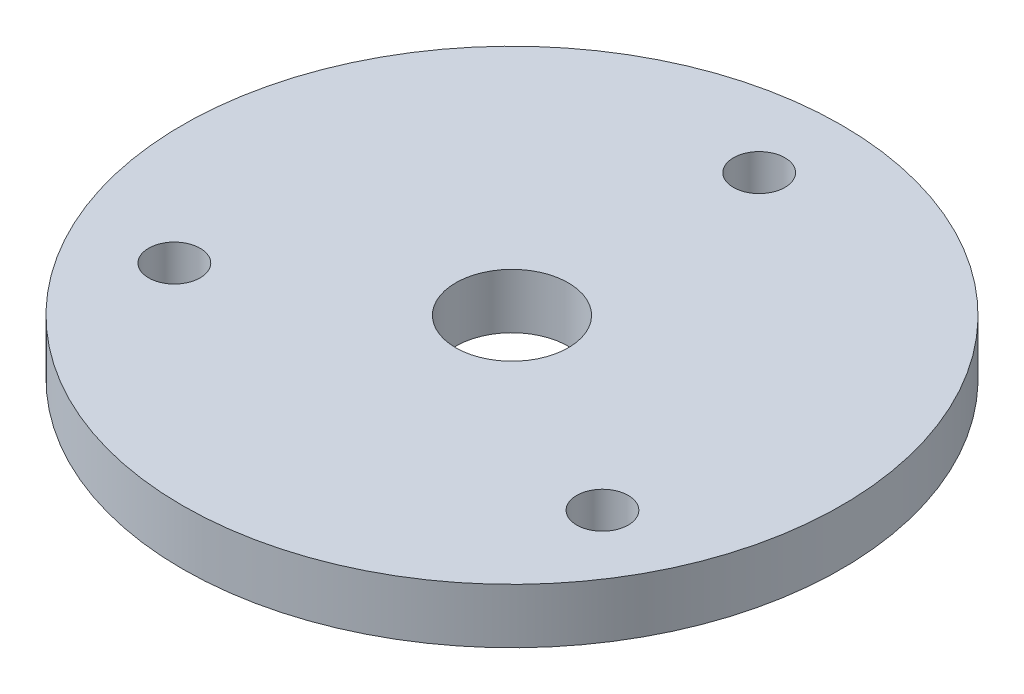
from build123d import *

# Parameters (mm, degrees)
SKETCH3_R                = 76.2
BOSS_EXTRUDE1_DEPTH      = 6.35
BOSS_EXTRUDE1_DEPTH_BACK = 6.35
SKETCH4_R                = 13.0175
SKETCH4_R_2              = 5.953125
CUT_EXTRUDE1_DEPTH       = 13.7


with BuildPart() as part:
    # Sketch3 → Boss-Extrude1 (new body, two sides)
    with BuildSketch(Plane(origin=(0, 0, 0), x_dir=(1, 0, 0), z_dir=(0, 1, 0))) as boss_extrude1_sk:
        Circle(SKETCH3_R)
    extrude(amount=BOSS_EXTRUDE1_DEPTH)
    extrude(boss_extrude1_sk.sketch, amount=-BOSS_EXTRUDE1_DEPTH_BACK)

    # Sketch4 → Cut-Extrude1 (cut, through all)
    with BuildSketch(Plane(origin=(0, 6.35, 0), x_dir=(1, 0, 0), z_dir=(0, 1, 0))):
        Circle(SKETCH4_R)
        with Locations((0, 57.15)):
            Circle(SKETCH4_R_2)
        with Locations((49.493351826, -28.575)):
            Circle(SKETCH4_R_2)
        with Locations((-49.493351826, -28.575)):
            Circle(SKETCH4_R_2)
    extrude(amount=-CUT_EXTRUDE1_DEPTH, mode=Mode.SUBTRACT)


solid = part.part
